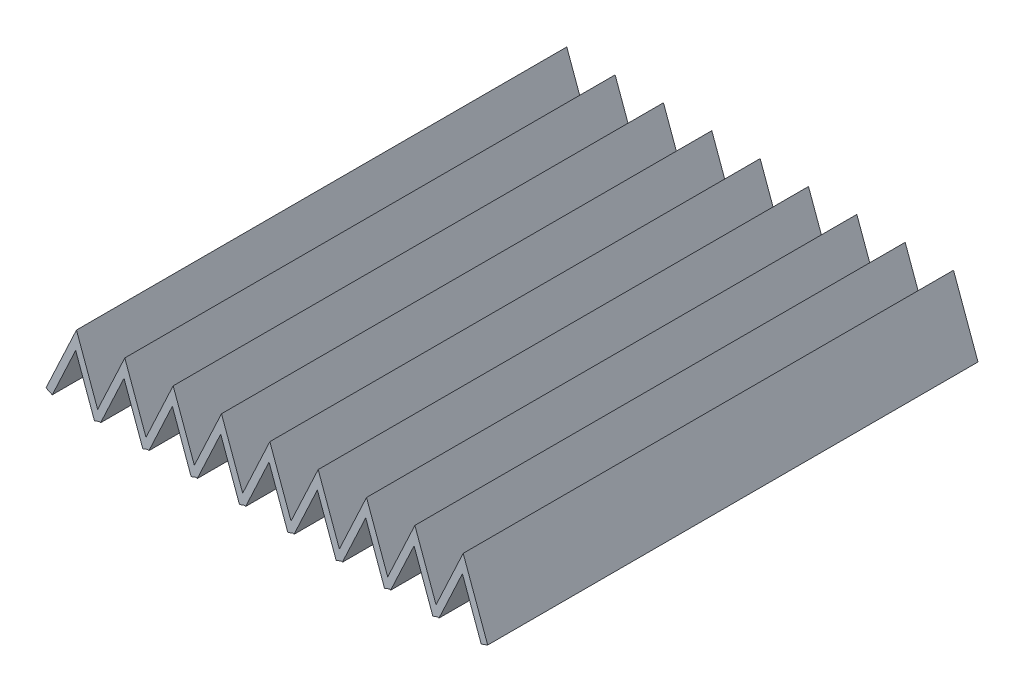
from build123d import *

# Parameters (mm, degrees)
EXTRUDE_THIN1_DEPTH  = 180.34
LPATTERN1_COUNT      = 2
LPATTERN1_PITCH      = 20.32
LPATTERN1_COUNT_DIR2 = 9
LPATTERN1_PITCH_DIR2 = 17.78


with BuildPart() as part:
    # Sketch1 → Extrude-Thin1 (new body)
    with BuildSketch(Plane.XY):
        Polygon((0, 0), (11.202174456, 24.023140647), (20.203364855, -0.707426722), (17.816545598, -1.576157886), (10.912657758, 17.392118062), (2.302021779, -1.073450385), align=None)
    extrude_thin1 = extrude(amount=-EXTRUDE_THIN1_DEPTH)

    # LPattern1: Extrude-Thin1 2 × 9, 9 skipped
    with Locations(*[(j * LPATTERN1_PITCH_DIR2, i * LPATTERN1_PITCH, 0) for i in range(LPATTERN1_COUNT) for j in range(LPATTERN1_COUNT_DIR2) if (i, j) not in ((0, 0), (1, 0), (1, 1), (1, 2), (1, 3), (1, 4), (1, 5), (1, 6), (1, 7), (1, 8))]):
        add(extrude_thin1)


solid = part.part
